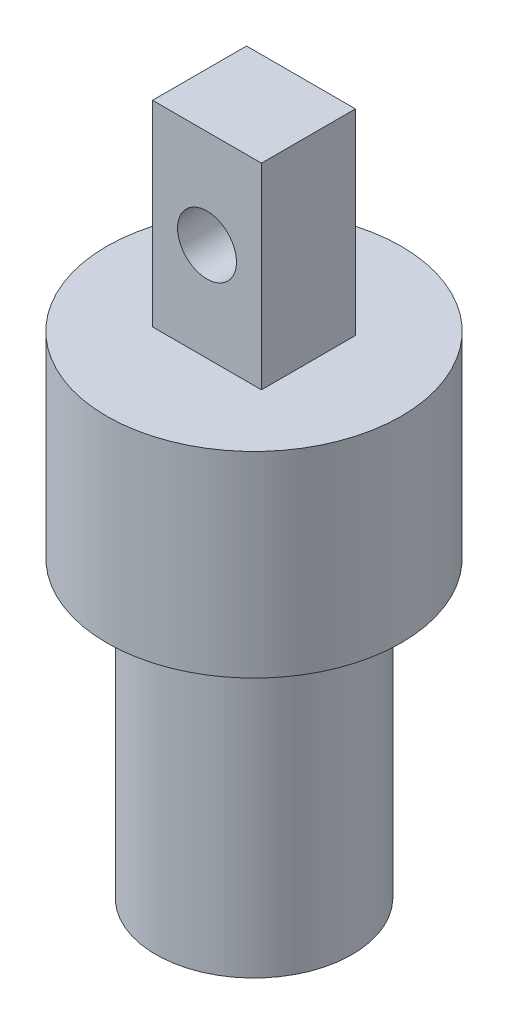
from build123d import *

# Parameters (mm, degrees)
SKETCH1_R           = 7.5
BOSS_EXTRUDE1_DEPTH = 10
SKETCH2_W           = 5.547326656
SKETCH2_H           = 4.788218798
BOSS_EXTRUDE2_DEPTH = 10
SKETCH4_R           = 1.5
CUT_EXTRUDE1_DEPTH  = 10
SKETCH5_R           = 5
BOSS_EXTRUDE3_DEPTH = 15


with BuildPart() as part:
    # Sketch1 → Boss-Extrude1 (new body)
    with BuildSketch(Plane(origin=(0, 0, 0), x_dir=(1, 0, 0), z_dir=(0, 1, 0))):
        Circle(SKETCH1_R)
    extrude(amount=BOSS_EXTRUDE1_DEPTH)

    # Sketch2 → Boss-Extrude2 (add)
    with BuildSketch(Plane(origin=(0, 10, 0), x_dir=(1, 0, 0), z_dir=(0, 1, 0))):
        Rectangle(SKETCH2_W, SKETCH2_H)
    extrude(amount=BOSS_EXTRUDE2_DEPTH)

    # Sketch4 → Cut-Extrude1 (cut)
    with BuildSketch(Plane(origin=(0, 0, -2.394109399), x_dir=(-1, 0, 0), z_dir=(0, 0, -1))):
        with Locations((0, 15)):
            Circle(SKETCH4_R)
    extrude(amount=-CUT_EXTRUDE1_DEPTH, mode=Mode.SUBTRACT)

    # Sketch5 → Boss-Extrude3 (add)
    with BuildSketch(Plane(origin=(0, 0, 0), x_dir=(-1, 0, 0), z_dir=(0, -1, 0))):
        Circle(SKETCH5_R)
    extrude(amount=BOSS_EXTRUDE3_DEPTH)


solid = part.part
